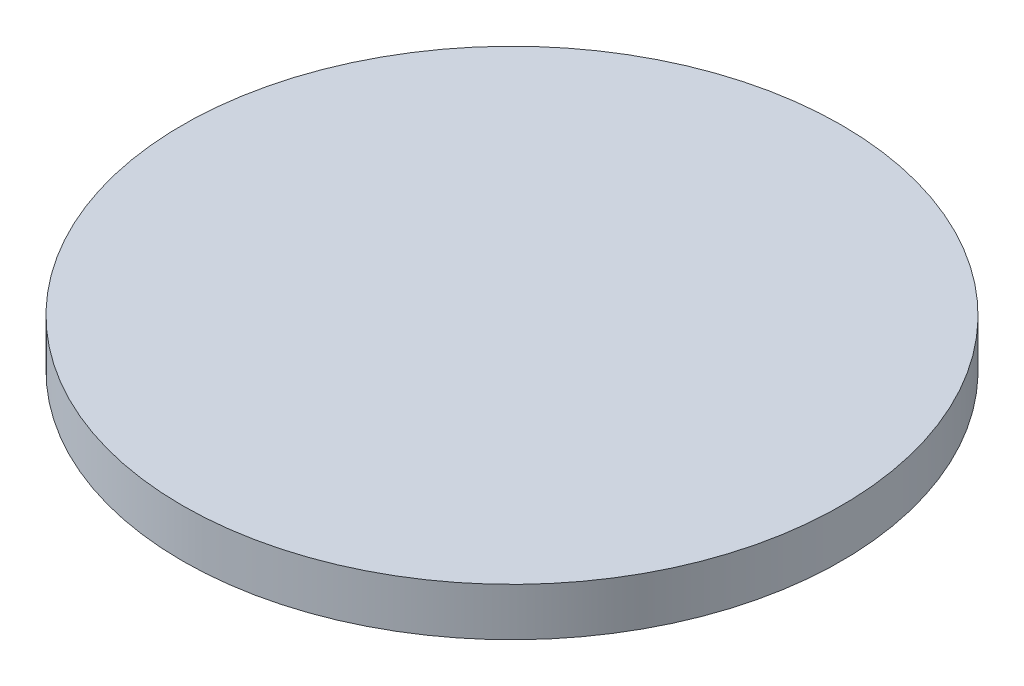
from build123d import *

# Parameters (mm, degrees)
SKETCH1_R           = 17.45
BOSS_EXTRUDE1_DEPTH = 2.54


with BuildPart() as part:
    # Sketch1 → Boss-Extrude1 (new body)
    with BuildSketch(Plane(origin=(0, 21.878326304, 0), x_dir=(1, 0, 0), z_dir=(0, 1, 0))):
        with Locations((91.816549827, -48.163081659)):
            Circle(SKETCH1_R)
    extrude(amount=BOSS_EXTRUDE1_DEPTH)


solid = part.part
